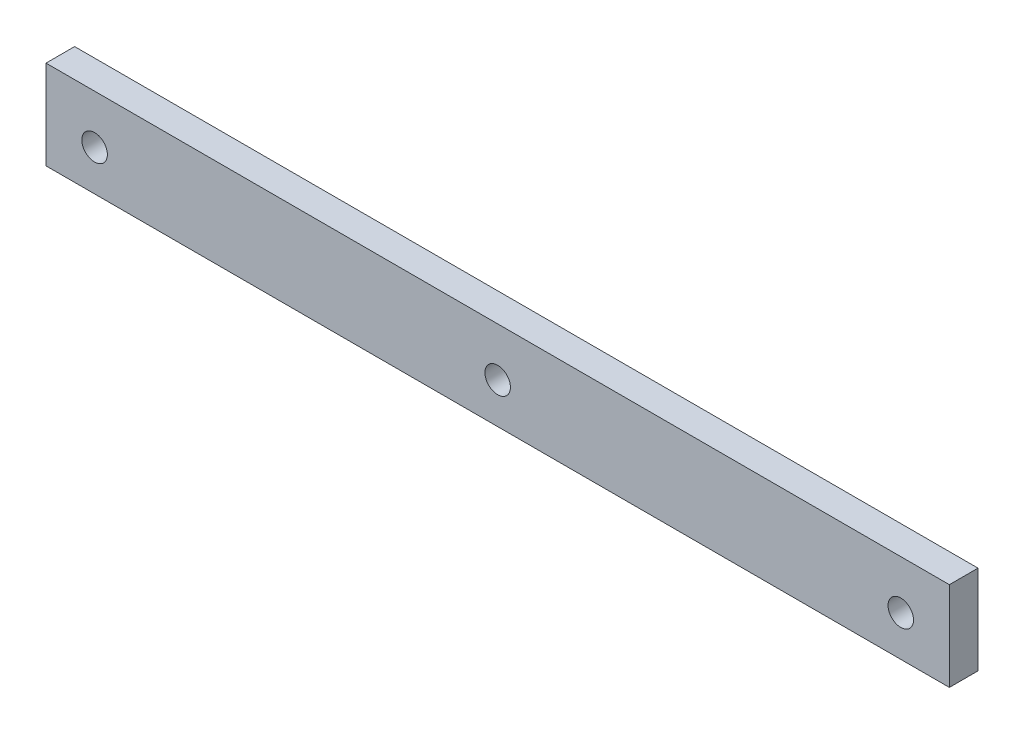
from build123d import *

# Parameters (mm, degrees)
SKETCH1_W           = 100.17
SKETCH1_H           = 9.87
BOSS_EXTRUDE1_DEPTH = 3.175
SKETCH2_R           = 1.415
CUT_EXTRUDE1_DEPTH  = 4.175
SKETCH3_R           = 1.415
CUT_EXTRUDE2_DEPTH  = 4.175


with BuildPart() as part:
    # Sketch1 → Boss-Extrude1 (new body)
    with BuildSketch(Plane.XY):
        Rectangle(SKETCH1_W, SKETCH1_H)
    extrude(amount=BOSS_EXTRUDE1_DEPTH)

    # Sketch2 → Cut-Extrude1 (cut, through all)
    with BuildSketch(Plane.XY.offset(3.175)):
        with Locations((-44.696699141, -0.453300859)):
            Circle(SKETCH2_R)
        with Locations((44.696699141, -0.453300859)):
            Circle(SKETCH2_R)
    extrude(amount=-CUT_EXTRUDE1_DEPTH, mode=Mode.SUBTRACT)

    # Sketch3 → Cut-Extrude2 (cut, through all)
    with BuildSketch(Plane.XY.offset(3.175)):
        with Locations((0, -0.453300859)):
            Circle(SKETCH3_R)
    extrude(amount=-CUT_EXTRUDE2_DEPTH, mode=Mode.SUBTRACT)


solid = part.part
